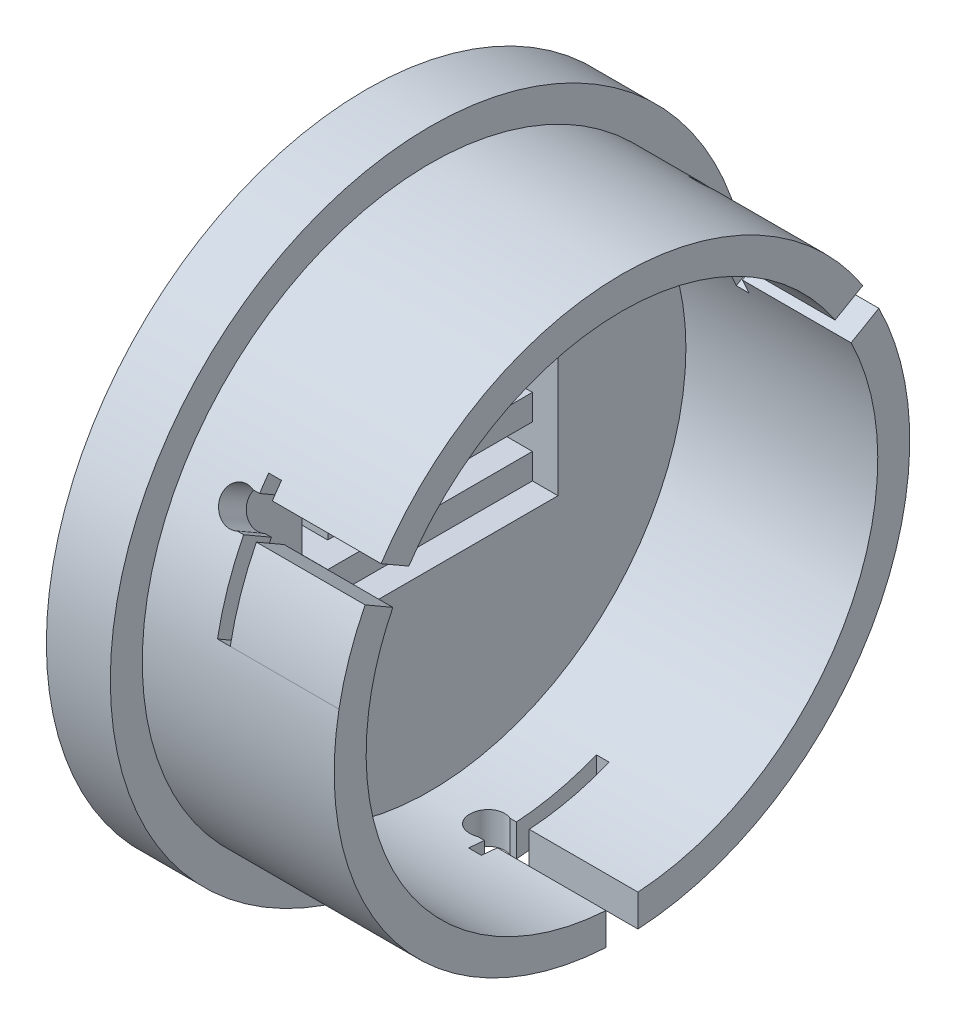
from build123d import *

# Parameters (mm, degrees)
SKETCH1_R           = 50
BOSS_EXTRUDE1_DEPTH = 5
SKETCH2_R           = 45
SKETCH2_R_2         = 40
BOSS_EXTRUDE2_DEPTH = 30
SKETCH7_R           = 37.5
BOSS_EXTRUDE5_DEPTH = 5
CUT_EXTRUDE5_DEPTH  = 79.89866919
SKETCH8_W           = 40
SKETCH8_H           = 20
SKETCH8_W_2         = 32
SKETCH8_H_2         = 12
SKETCH8_H_3         = 4
CUT_EXTRUDE4_DEPTH  = 40
CIRPATTERN6_COUNT   = 3


with BuildPart() as part:
    # Sketch1 → Boss-Extrude1 (new, symmetric)
    with BuildSketch(Plane(origin=(0, 0, 0), x_dir=(0, 0, -1), z_dir=(1, 0, 0))):
        Circle(SKETCH1_R)
    extrude(amount=BOSS_EXTRUDE1_DEPTH, both=True)

    # Sketch2 → Boss-Extrude2 (add)
    with BuildSketch(Plane(origin=(5, 0, 0), x_dir=(0, 0, -1), z_dir=(1, 0, 0))):
        Circle(SKETCH2_R)
        Circle(SKETCH2_R_2, mode=Mode.SUBTRACT)
    extrude(amount=BOSS_EXTRUDE2_DEPTH)

    # Sketch7 → Boss-Extrude5 (add)
    with BuildSketch(Plane.ZY.offset(5)):
        with Locations(Location((0, 0, 0), (0, 0, 180))):
            Circle(SKETCH7_R)
    extrude(amount=BOSS_EXTRUDE5_DEPTH)

    # Sketch6 → Cut-Extrude5 (cut, through all)
    with BuildSketch(Plane(origin=(0, 0, 0), x_dir=(1, 0, 0), z_dir=(0, 1, 0))):
        with BuildLine():
            Line((18, -2.5), (55, -2.5))
            Line((55, -2.5), (55, 0))
            Line((55, 0), (55, 2.5))
            Line((55, 2.5), (18, 2.5))
            Line((18, 2.5), (18, 15))
            Line((18, 15), (16, 15))
            Line((16, 15), (16, 2.5))
            Line((16, 2.5), (15, 2.5))
            ThreePointArc((15, 2.5), (11.203450847, 0), (15, -2.5))
            Line((15, -2.5), (16, -2.5))
            Line((16, -2.5), (16, -5))
            Line((16, -5), (18, -5))
            Line((18, -5), (18, -2.5))
        make_face()
    cut_extrude5 = extrude(amount=-CUT_EXTRUDE5_DEPTH, mode=Mode.SUBTRACT)

    # Sketch8 → Cut-Extrude4 (cut)
    with BuildSketch(Plane.ZY.offset(10)):
        Rectangle(SKETCH8_W, SKETCH8_H)
        Rectangle(SKETCH8_W_2, SKETCH8_H_2, mode=Mode.SUBTRACT)
        Rectangle(SKETCH8_W_2, SKETCH8_H_3)
    extrude(amount=-CUT_EXTRUDE4_DEPTH, mode=Mode.SUBTRACT)


with BuildPart() as cut_extrude4_piece_1:
    # of the separate pieces the step leaves, piece 1, a body of its own (cut_extrude4_pieces)
    add(part.part.solids().sort_by_distance((-5, 0, -50))[0])

    # CirPattern6: Cut-Extrude5 ×3 about axis
    cirpattern6_axis = Axis((0, 0, 0), (1, 0, 0))
    for i in range(1, CIRPATTERN6_COUNT):
        add(cut_extrude5.rotate(cirpattern6_axis, i * 360 / CIRPATTERN6_COUNT), mode=Mode.SUBTRACT)


with BuildPart() as cut_extrude4_piece_2:
    # of the separate pieces the step leaves, piece 2, a body of its own (cut_extrude4_pieces)
    add(part.part.solids().sort_by_distance((-10, -6, -16))[0])


with BuildPart() as cut_extrude4_piece_3:
    # of the separate pieces the step leaves, piece 3, a body of its own (cut_extrude4_pieces)
    add(part.part.solids().sort_by_distance((-10, 2, 16))[0])


solid = Compound([cut_extrude4_piece_1.part, cut_extrude4_piece_2.part, cut_extrude4_piece_3.part])
